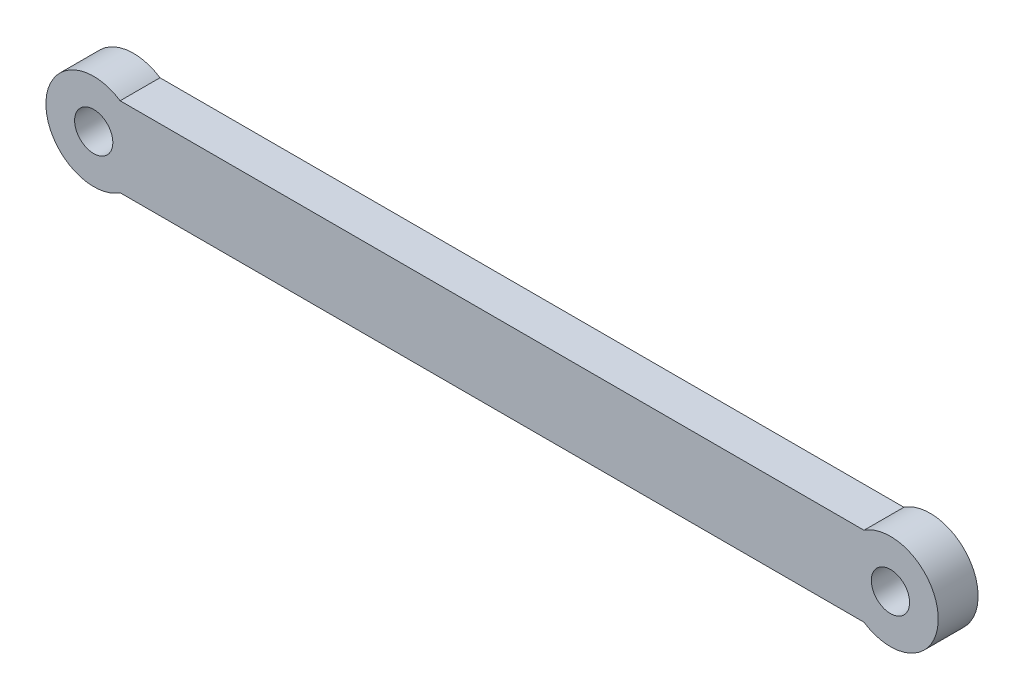
from build123d import *

# Parameters (mm, degrees)
SKETCH14_R          = 1.2
BOSS_EXTRUDE1_DEPTH = 2.5
SKETCH15_R          = 3
SKETCH15_R_2        = 1.2
BOSS_EXTRUDE2_DEPTH = 2.5


with BuildPart() as part:
    # Sketch14 → Boss-Extrude1 (new body)
    with BuildSketch(Plane.XY):
        with BuildLine():
            Line((50, 2.5), (0, 2.5))
            ThreePointArc((0, 2.5), (-2.5, 0), (0, -2.5))
            Line((0, -2.5), (50, -2.5))
            ThreePointArc((50, -2.5), (52.5, 0), (50, 2.5))
        make_face()
        Circle(SKETCH14_R, mode=Mode.SUBTRACT)
        with Locations((50, 0)):
            Circle(SKETCH14_R, mode=Mode.SUBTRACT)
    extrude(amount=BOSS_EXTRUDE1_DEPTH)

    # Sketch15 → Boss-Extrude2 (add)
    with BuildSketch(Plane.XY.offset(2.5)):
        with Locations((50, 0)):
            Circle(SKETCH15_R)
        with Locations((50, 0)):
            Circle(SKETCH15_R_2, mode=Mode.SUBTRACT)
        Circle(SKETCH15_R)
        Circle(SKETCH15_R_2, mode=Mode.SUBTRACT)
    extrude(amount=-BOSS_EXTRUDE2_DEPTH)


solid = part.part
